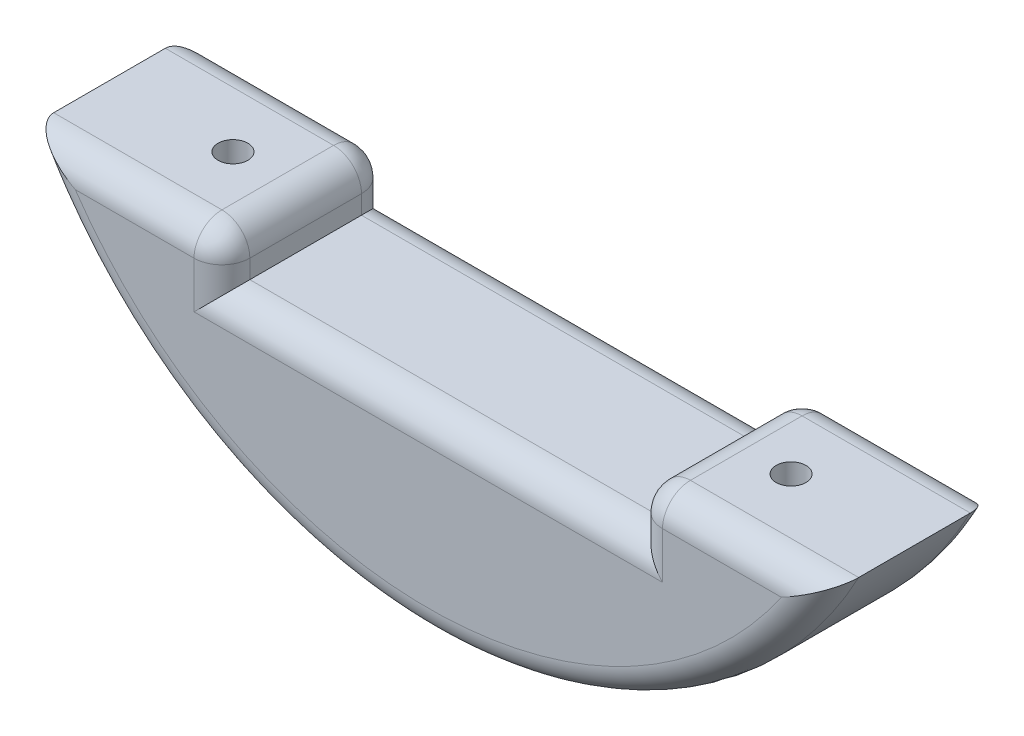
from build123d import *

# Parameters (mm, degrees)
SKETCH1_W           = 44.362146026
SKETCH1_H           = 10
BOSS_EXTRUDE1_DEPTH = 18
SKETCH2_R           = 1.6
CUT_EXTRUDE1_DEPTH  = 27
CUT_EXTRUDE2_START  = -17.925297
SKETCH3_R           = 3.05
CUT_EXTRUDE2_DEPTH  = 12.925297
FILLET1_R           = 3


with BuildPart() as part:
    # Sketch1 → Boss-Extrude1 (new body)
    with BuildSketch(Plane.XY):
        with BuildLine():
            Line((-29.953929645, -23), (-37.509998667, -23))
            ThreePointArc((-37.509998667, -23), (-35.812927639, -25.562359318), (-33.941125497, -28))
            Line((-33.941125497, -28), (-22.181073013, -28))
            Line((-22.181073013, -28), (-22.181073013, -23))
            Line((-22.181073013, -23), (-29.953929645, -23))
        make_face()
        with BuildLine():
            Line((-37.509998667, -23), (-43.266615306, -23))
            ThreePointArc((-43.266615306, -23), (0, -49), (43.266615306, -23))
            Line((43.266615306, -23), (37.509998667, -23))
            ThreePointArc((37.509998667, -23), (35.812927639, -25.562359318), (33.941125497, -28))
            ThreePointArc((33.941125497, -28), (28.503075122, -33.519765939), (22.181073013, -38))
            ThreePointArc((22.181073013, -38), (0, -44), (-22.181073013, -38))
            ThreePointArc((-22.181073013, -38), (-28.503075122, -33.519765939), (-33.941125497, -28))
            ThreePointArc((-33.941125497, -28), (-35.812927639, -25.562359318), (-37.509998667, -23))
        make_face()
        with BuildLine():
            Line((-22.181073013, -28), (-33.941125497, -28))
            ThreePointArc((-33.941125497, -28), (-28.503075122, -33.519765939), (-22.181073013, -38))
            Line((-22.181073013, -38), (-22.181073013, -28))
        make_face()
        with BuildLine():
            ThreePointArc((22.181073013, -38), (28.503075122, -33.519765939), (33.941125497, -28))
            Line((33.941125497, -28), (22.181073013, -28))
            Line((22.181073013, -28), (22.181073013, -38))
        make_face()
        with BuildLine():
            ThreePointArc((33.941125497, -28), (35.812927639, -25.562359318), (37.509998667, -23))
            Line((37.509998667, -23), (22.181073013, -23))
            Line((22.181073013, -23), (22.181073013, -28))
            Line((22.181073013, -28), (33.941125497, -28))
        make_face()
        with Locations((0, -33)):
            Rectangle(SKETCH1_W, SKETCH1_H)
        with BuildLine():
            Line((22.181073013, -38), (-22.181073013, -38))
            ThreePointArc((-22.181073013, -38), (0, -44), (22.181073013, -38))
        make_face()
    extrude(amount=BOSS_EXTRUDE1_DEPTH)

    # Sketch2 → Cut-Extrude1 (cut, through all)
    with BuildSketch(Plane(origin=(0, -23, 0), x_dir=(1, 0, 0), z_dir=(0, 1, 0))):
        with Locations((-29.996615306, -9)):
            Circle(SKETCH2_R)
    cut_extrude1 = extrude(amount=-CUT_EXTRUDE1_DEPTH, mode=Mode.SUBTRACT)

    # Sketch3 → Cut-Extrude2 (cut)
    with BuildSketch(Plane(origin=(0, -23, 0), x_dir=(1, 0, 0), z_dir=(0, 1, 0)).offset(CUT_EXTRUDE2_START)):
        with Locations((-29.996615306, -9)):
            Circle(SKETCH3_R)
    cut_extrude2 = extrude(amount=CUT_EXTRUDE2_DEPTH, mode=Mode.SUBTRACT)

    # Mirror1: Cut-Extrude1, Cut-Extrude2 across plane
    add(cut_extrude1.mirror(Plane(origin=(0, 0, 0), x_dir=(0, 0, 1), z_dir=(1, 0, 0))), mode=Mode.SUBTRACT)
    add(cut_extrude2.mirror(Plane(origin=(0, 0, 0), x_dir=(0, 0, 1), z_dir=(1, 0, 0))), mode=Mode.SUBTRACT)

    # Fillet1
    fillet1_edges = [part.edges().sort_by_distance(p)[0] for p in [
        (0, -28, 18),
        (0, -28, 0),
        (22.181073013, -25.5, 0),
        (22.181073013, -23, 9),
        (-22.181073013, -23, 9),
        (-22.181073013, -25.5, 18),
        (-32.723844159, -23, 18),
        (0, -49, 18),
        (32.723844159, -23, 18),
        (22.181073013, -25.5, 18),
        (32.723844159, -23, 0),
        (0, -49, 0),
        (-32.723844159, -23, 0),
        (-22.181073013, -25.5, 0),
    ]]
    fillet(fillet1_edges, radius=FILLET1_R)


solid = part.part
